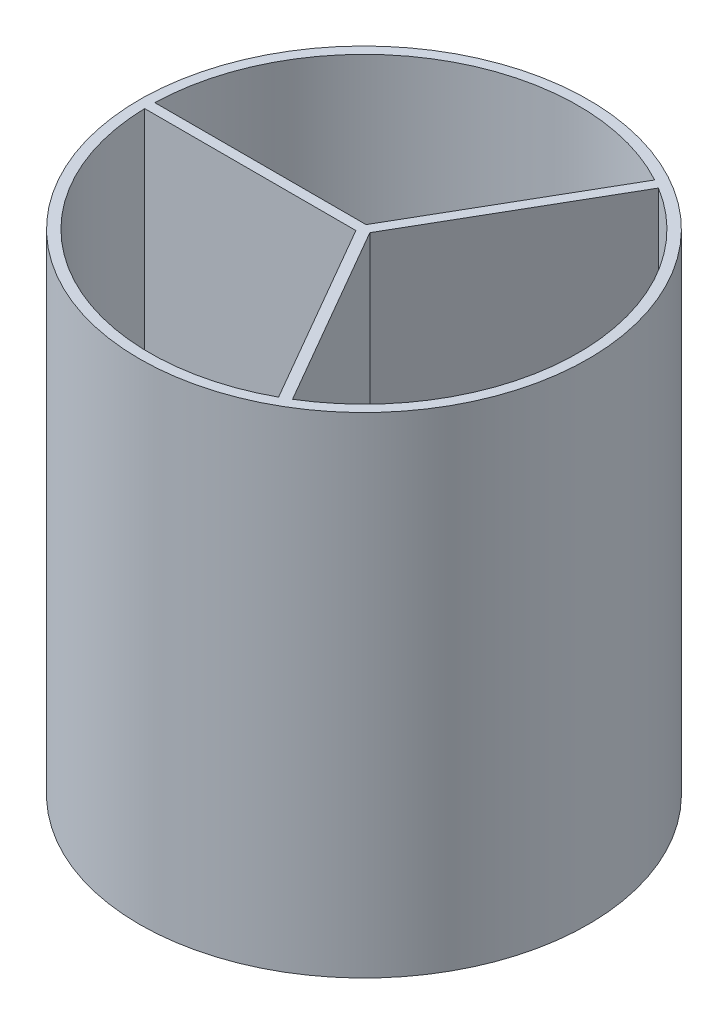
from build123d import *

# Parameters (mm, degrees)
SKETCH1_R           = 279.4
BOSS_EXTRUDE1_DEPTH = 609.6
CUT_EXTRUDE1_DEPTH  = 596.9
SKETCH4_R           = 12.7
BOSS_EXTRUDE2_DEPTH = 25.4


with BuildPart() as part:
    # Sketch1 → Boss-Extrude1 (new body)
    with BuildSketch(Plane(origin=(0, 0, 0), x_dir=(1, 0, 0), z_dir=(0, 1, 0))):
        Circle(SKETCH1_R)
    extrude(amount=BOSS_EXTRUDE1_DEPTH)

    # Sketch3 → Cut-Extrude1 (cut)
    with BuildSketch(Plane(origin=(0, 609.6, 0), x_dir=(1, 0, 0), z_dir=(0, 1, 0))):
        with BuildLine():
            ThreePointArc((127.809487072, 234.080381524), (-133.353402796, 230.967010551), (-266.624487569, 6.346071887))
            Line((-266.624487569, 6.346071887), (-3.672977901, 6.346071887))
            Line((-3.672977901, 6.346071887), (127.809487072, 234.080381524))
        make_face()
        with BuildLine():
            Line((-3.659370518, -6.353928113), (-266.624300463, -6.353928113))
            ThreePointArc((-266.624300463, -6.353928113), (-133.346597175, -230.970939778), (127.816384316, -234.07661545))
            Line((127.816384316, -234.07661545), (-3.659370518, -6.353928113))
        make_face()
        with BuildLine():
            ThreePointArc((266.7, 0), (232.539255974, 130.592436348), (138.808103253, 227.730543563))
            Line((138.808103253, 227.730543563), (7.332348419, 0.007856226))
            Line((7.332348419, 0.007856226), (138.814813391, -227.726453411))
            ThreePointArc((138.814813391, -227.726453411), (232.541179935, -130.589010389), (266.7, 0))
        make_face()
    extrude(amount=-CUT_EXTRUDE1_DEPTH, mode=Mode.SUBTRACT)

    # Sketch4 → Boss-Extrude2 (add)
    with BuildSketch(Plane.XZ):
        Circle(SKETCH4_R)
    extrude(amount=BOSS_EXTRUDE2_DEPTH)


solid = part.part
